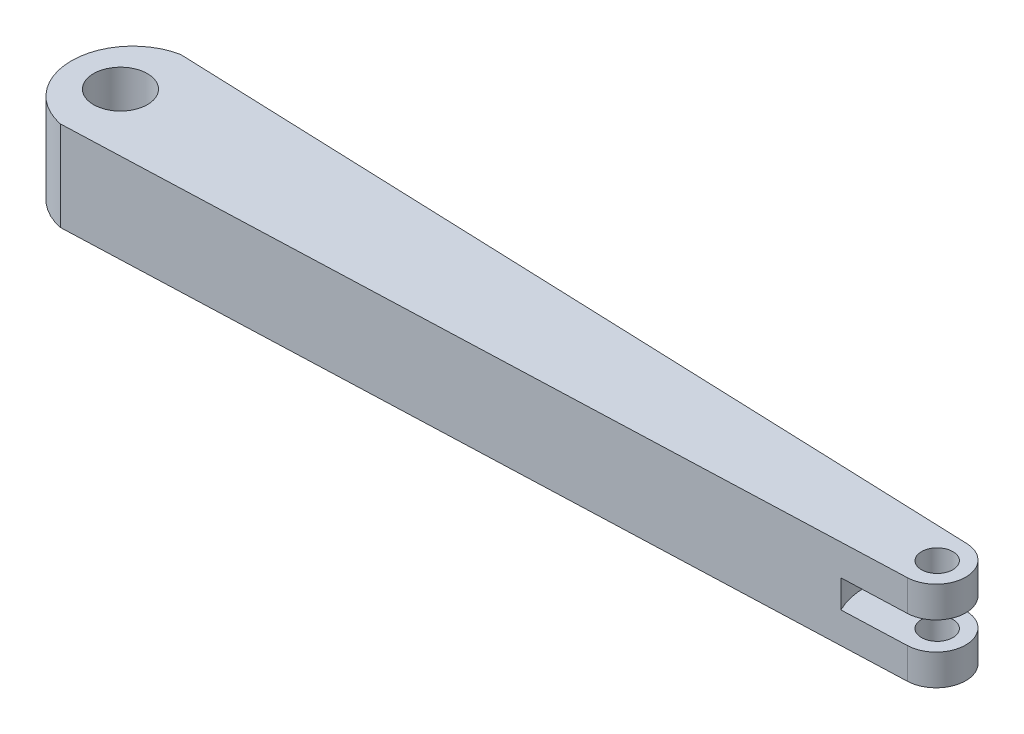
from build123d import *

# Parameters (mm, degrees)
SKETCH1_R           = 1.75
SKETCH1_R_2         = 3
BOSS_EXTRUDE1_DEPTH = 10
SKETCH2_W           = 8
SKETCH2_H           = 3.1


with BuildPart() as part:
    # Sketch1 → Boss-Extrude1 (new body)
    with BuildSketch(Plane(origin=(0, 0, 0), x_dir=(1, 0, 0), z_dir=(0, 1, 0))):
        with BuildLine():
            Line((-24.049180328, 6.7), (66.950819672, 3.3))
            ThreePointArc((66.950819672, 3.3), (70.129825511, 0), (66.950819672, -3.3))
            Line((66.950819672, -3.3), (-24.049180328, -6.7))
            ThreePointArc((-24.049180328, -6.7), (-29.521356494, 0), (-24.049180328, 6.7))
        make_face()
        with Locations((66.950819672, 0)):
            Circle(SKETCH1_R, mode=Mode.SUBTRACT)
        with Locations((-24.049180328, 0)):
            Circle(SKETCH1_R_2, mode=Mode.SUBTRACT)
    extrude(amount=BOSS_EXTRUDE1_DEPTH)

    # Sketch2 → Cut-Revolve1 (revolve, cut)
    with BuildSketch(Plane(origin=(66.950819672, 0, 0), x_dir=(0, 0, -1), z_dir=(1, 0, 0))):
        with Locations((4, 5)):
            Rectangle(SKETCH2_W, SKETCH2_H)
    revolve(axis=Axis((66.950819672, 3.45, 0), (0, 1, 0)), mode=Mode.SUBTRACT)


solid = part.part
